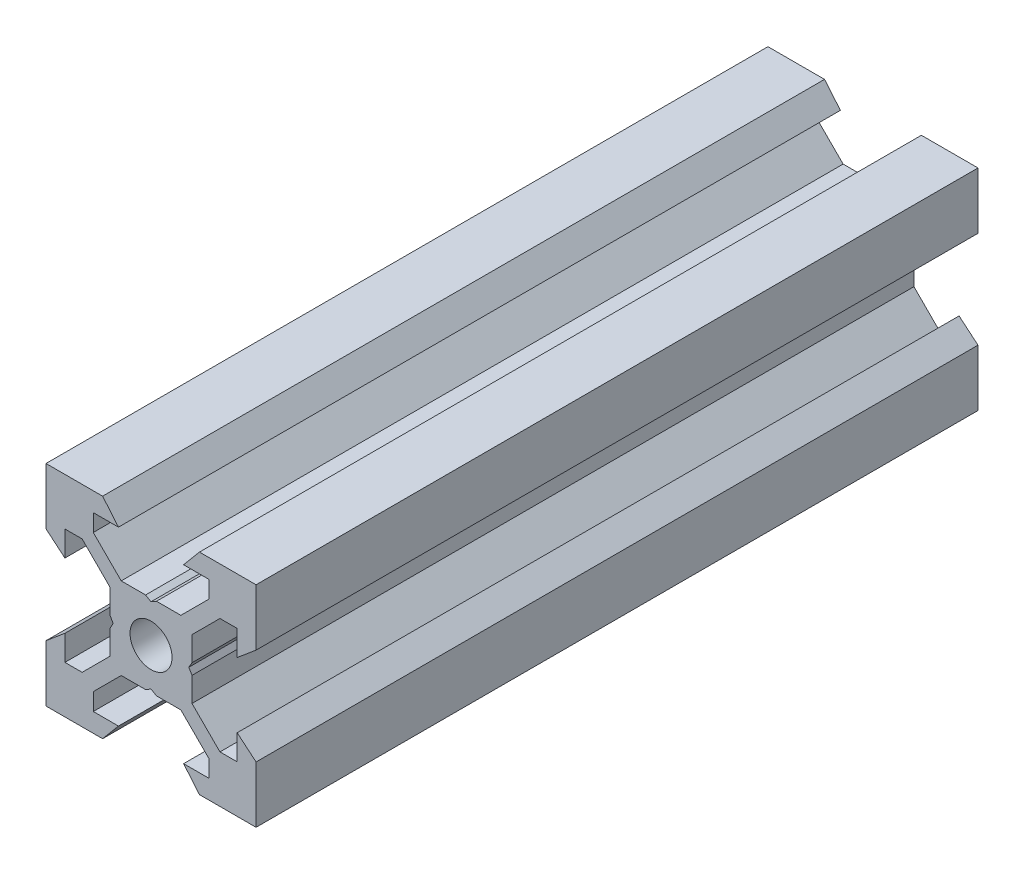
from build123d import *

# Parameters (mm, degrees)
SKETCH1_R           = 2
BOSS_EXTRUDE1_DEPTH = 34.365


with BuildPart() as part:
    # Sketch1 → Boss-Extrude1 (new body, symmetric)
    with BuildSketch(Plane.XY):
        Polygon((10, 10), (10, 4.610379336), (8.2, 3.1), (8.2, 5.5), (6.560660172, 5.5), (3.9, 2.839339828), (3.9, 0.519615242), (3.6, 0), (3.9, -0.519615242), (3.9, -2.839339828), (6.560660172, -5.5), (8.2, -5.5), (8.2, -3.1), (10, -4.610379336), (10, -10), (4.610379336, -10), (3.1, -8.2), (5.5, -8.2), (5.5, -6.560660172), (2.839339828, -3.9), (0.519615242, -3.9), (0, -3.6), (-0.519615242, -3.9), (-2.839339828, -3.9), (-5.5, -6.560660172), (-5.5, -8.2), (-3.1, -8.2), (-4.610379336, -10), (-10, -10), (-10, -4.610379336), (-8.2, -3.1), (-8.2, -5.5), (-6.560660172, -5.5), (-3.9, -2.839339828), (-3.9, -0.519615242), (-3.6, 0), (-3.9, 0.519615242), (-3.9, 2.839339828), (-6.560660172, 5.5), (-8.2, 5.5), (-8.2, 3.1), (-10, 4.610379336), (-10, 10), (-4.610379336, 10), (-3.1, 8.2), (-5.5, 8.2), (-5.5, 6.560660172), (-2.839339828, 3.9), (-0.519615242, 3.9), (0, 3.6), (0.519615242, 3.9), (2.839339828, 3.9), (5.5, 6.560660172), (5.5, 8.2), (3.1, 8.2), (4.610379336, 10), align=None)
        Circle(SKETCH1_R, mode=Mode.SUBTRACT)
    extrude(amount=BOSS_EXTRUDE1_DEPTH, both=True)


solid = part.part
